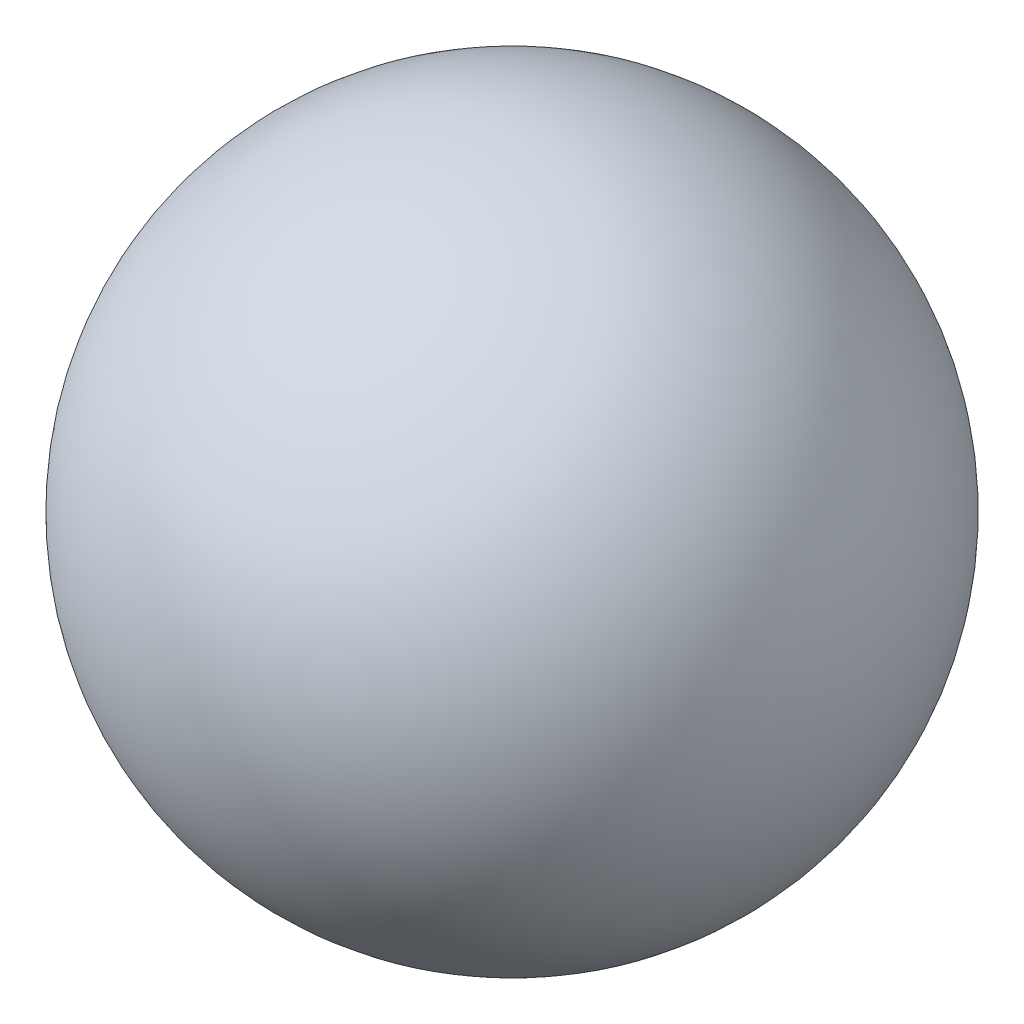
from build123d import *


with BuildPart() as part:
    # 草图1 → 旋转1 (revolve)
    with BuildSketch(Plane.XY):
        with BuildLine():
            Line((0, 20), (0, -20))
            ThreePointArc((0, -20), (20, 0), (0, 20))
        make_face()
    revolve(axis=Axis((0, 20, 0), (0, -1, 0)))


solid = part.part
